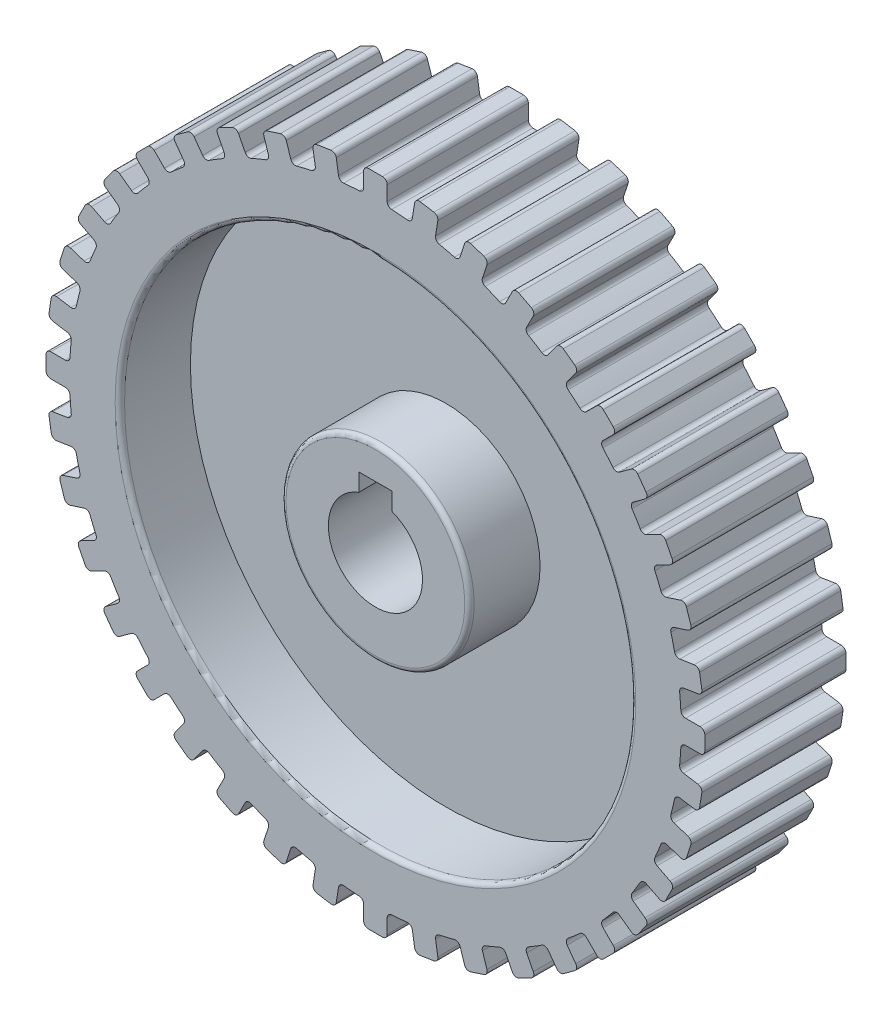
from build123d import *

# Parameters (mm, degrees)
BOSS_EXTRUDE1_DEPTH = 30
CUT_EXTRUDE1_DEPTH  = 30
SKETCH3_R           = 54.321512685
SKETCH3_R_2         = 20
CUT_EXTRUDE2_DEPTH  = 15
FILLET2_R           = 1
FILLET3_R           = 1


with BuildPart() as part:
    # Sketch1 → Boss-Extrude1 (new body)
    with BuildSketch(Plane.XY):
        with BuildLine():
            Line((8.324757236, 68.541581664), (7.840926028, 65.486791638))
            ThreePointArc((7.840926028, 65.486791638), (7.462274894, 64.85008445), (6.749400752, 64.648631768))
            ThreePointArc((6.749400752, 64.648631768), (5.099841222, 64.799626693), (3.446969697, 64.908538729))
            ThreePointArc((3.446969697, 64.908538729), (2.774386362, 65.219029279), (2.5, 65.907131632))
            Line((2.5, 65.907131632), (2.5, 69))
            ThreePointArc((2.5, 69), (2.207106781, 69.707106781), (1.5, 70))
            Line((1.5, 70), (-1.5, 70))
            ThreePointArc((-1.5, 70), (-2.207106781, 69.707106781), (-2.5, 69))
            Line((-2.5, 69), (-2.5, 65.907131632))
            ThreePointArc((-2.5, 65.907131632), (-2.774386362, 65.219029279), (-3.446969697, 64.908538729))
            ThreePointArc((-3.446969697, 64.908538729), (-5.099841222, 64.799626693), (-6.749400753, 64.648631768))
            ThreePointArc((-6.749400753, 64.648631768), (-7.462274894, 64.85008445), (-7.840926028, 65.486791638))
            Line((-7.840926028, 65.486791638), (-8.324757236, 68.541581664))
            ThreePointArc((-8.324757236, 68.541581664), (-8.724660325, 69.194164193), (-9.468880042, 69.372835539))
            Line((-9.468880042, 69.372835539), (-12.431945064, 68.903532144))
            ThreePointArc((-12.431945064, 68.903532144), (-13.084527593, 68.503629056), (-13.263198939, 67.759409339))
            Line((-13.263198939, 67.759409339), (-12.779367731, 64.704619313))
            ThreePointArc((-12.779367731, 64.704619313), (-12.942733018, 63.982065158), (-13.558464313, 63.570182047))
            ThreePointArc((-13.558464313, 63.570182047), (-15.173948651, 63.204044826), (-16.779578555, 62.796860937))
            ThreePointArc((-16.779578555, 62.796860937), (-17.515190176, 62.884315317), (-17.988782434, 63.453949495))
            Line((-17.988782434, 63.453949495), (-18.944531321, 66.39544211))
            ThreePointArc((-18.944531321, 66.39544211), (-19.441597338, 66.97743164), (-20.204604832, 67.037481632))
            Line((-20.204604832, 67.037481632), (-23.057774381, 66.110430649))
            ThreePointArc((-23.057774381, 66.110430649), (-23.639763911, 65.613364633), (-23.699813903, 64.850357138))
            Line((-23.699813903, 64.850357138), (-22.744065016, 61.908864523))
            ThreePointArc((-22.744065016, 61.908864523), (-22.792386632, 61.169650248), (-23.336104539, 60.666516506))
            ThreePointArc((-23.336104539, 60.666516506), (-24.874423104, 60.052169613), (-26.396587446, 59.398822978))
            ThreePointArc((-26.396587446, 59.398822978), (-27.136823346, 59.37012564), (-27.693695316, 59.858660524))
            Line((-27.693695316, 59.858660524), (-29.097828172, 62.614426418))
            ThreePointArc((-29.097828172, 62.614426418), (-29.679817701, 63.111492435), (-30.442825196, 63.051442443))
            Line((-30.442825196, 63.051442443), (-33.115844768, 61.689470944))
            ThreePointArc((-33.115844768, 61.689470944), (-33.612910785, 61.107481414), (-33.552860793, 60.34447392))
            Line((-33.552860793, 60.34447392), (-32.148727937, 57.588708026))
            ThreePointArc((-32.148727937, 57.588708026), (-32.080816044, 56.851035538), (-32.539132424, 56.269039988))
            ThreePointArc((-32.539132424, 56.269039988), (-33.962406707, 55.421610683), (-35.363624749, 54.538188865))
            ThreePointArc((-35.363624749, 54.538188865), (-36.090257863, 54.394046431), (-36.716697508, 54.789452672))
            Line((-36.716697508, 54.789452672), (-38.534639922, 57.291635743))
            ThreePointArc((-38.534639922, 57.291635743), (-39.187222452, 57.691538831), (-39.931442169, 57.512867485))
            Line((-39.931442169, 57.512867485), (-42.358493152, 55.749511728))
            ThreePointArc((-42.358493152, 55.749511728), (-42.75839624, 55.096929199), (-42.579724894, 54.352709481))
            Line((-42.579724894, 54.352709481), (-40.76178248, 51.85052641))
            ThreePointArc((-40.76178248, 51.85052641), (-40.579309295, 51.132559656), (-40.940938877, 50.486032959))
            ThreePointArc((-40.940938877, 50.486032959), (-42.214123142, 49.426387764), (-43.459892245, 48.334643539))
            ThreePointArc((-43.459892245, 48.334643539), (-44.155030455, 48.078605276), (-44.835612753, 48.371146659))
            Line((-44.835612753, 48.371146659), (-47.022600949, 50.558134855))
            ThreePointArc((-47.022600949, 50.558134855), (-47.72970773, 50.851028074), (-48.436814511, 50.558134855))
            Line((-48.436814511, 50.558134855), (-50.558134855, 48.436814511))
            ThreePointArc((-50.558134855, 48.436814511), (-50.851028074, 47.72970773), (-50.558134855, 47.022600949))
            Line((-50.558134855, 47.022600949), (-48.371146659, 44.835612753))
            ThreePointArc((-48.371146659, 44.835612753), (-48.078605276, 44.155030455), (-48.334643539, 43.459892245))
            ThreePointArc((-48.334643539, 43.459892245), (-49.426387764, 42.214123141), (-50.486032959, 40.940938877))
            ThreePointArc((-50.486032959, 40.940938877), (-51.132559656, 40.579309295), (-51.85052641, 40.76178248))
            Line((-51.85052641, 40.76178248), (-54.352709481, 42.579724894))
            ThreePointArc((-54.352709481, 42.579724894), (-55.096929199, 42.75839624), (-55.749511728, 42.358493152))
            Line((-55.749511728, 42.358493152), (-57.512867485, 39.931442169))
            ThreePointArc((-57.512867485, 39.931442169), (-57.691538831, 39.187222452), (-57.291635743, 38.534639922))
            Line((-57.291635743, 38.534639922), (-54.789452672, 36.716697508))
            ThreePointArc((-54.789452672, 36.716697508), (-54.394046431, 36.090257863), (-54.538188865, 35.363624749))
            ThreePointArc((-54.538188865, 35.363624749), (-55.421610683, 33.962406707), (-56.269039988, 32.539132424))
            ThreePointArc((-56.269039988, 32.539132424), (-56.851035538, 32.080816044), (-57.588708026, 32.148727937))
            Line((-57.588708026, 32.148727937), (-60.34447392, 33.552860793))
            ThreePointArc((-60.34447392, 33.552860793), (-61.107481414, 33.612910785), (-61.689470944, 33.115844768))
            Line((-61.689470944, 33.115844768), (-63.051442443, 30.442825196))
            ThreePointArc((-63.051442443, 30.442825196), (-63.111492435, 29.679817701), (-62.614426418, 29.097828172))
            Line((-62.614426418, 29.097828172), (-59.858660524, 27.693695316))
            ThreePointArc((-59.858660524, 27.693695316), (-59.37012564, 27.136823346), (-59.398822978, 26.396587446))
            ThreePointArc((-59.398822978, 26.396587446), (-60.052169613, 24.874423104), (-60.666516506, 23.336104539))
            ThreePointArc((-60.666516506, 23.336104539), (-61.169650248, 22.792386632), (-61.908864523, 22.744065016))
            Line((-61.908864523, 22.744065016), (-64.850357138, 23.699813903))
            ThreePointArc((-64.850357138, 23.699813903), (-65.613364633, 23.639763911), (-66.110430649, 23.057774381))
            Line((-66.110430649, 23.057774381), (-67.037481632, 20.204604832))
            ThreePointArc((-67.037481632, 20.204604832), (-66.97743164, 19.441597338), (-66.39544211, 18.944531321))
            Line((-66.39544211, 18.944531321), (-63.453949495, 17.988782434))
            ThreePointArc((-63.453949495, 17.988782434), (-62.884315317, 17.515190176), (-62.796860937, 16.779578555))
            ThreePointArc((-62.796860937, 16.779578555), (-63.204044826, 15.173948651), (-63.570182047, 13.558464313))
            ThreePointArc((-63.570182047, 13.558464313), (-63.982065158, 12.942733018), (-64.704619313, 12.779367731))
            Line((-64.704619313, 12.779367731), (-67.759409339, 13.263198939))
            ThreePointArc((-67.759409339, 13.263198939), (-68.503629056, 13.084527593), (-68.903532144, 12.431945064))
            Line((-68.903532144, 12.431945064), (-69.372835539, 9.468880042))
            ThreePointArc((-69.372835539, 9.468880042), (-69.194164193, 8.724660325), (-68.541581664, 8.324757236))
            Line((-68.541581664, 8.324757236), (-65.486791638, 7.840926028))
            ThreePointArc((-65.486791638, 7.840926028), (-64.85008445, 7.462274894), (-64.648631768, 6.749400752))
            ThreePointArc((-64.648631768, 6.749400752), (-64.799626693, 5.099841222), (-64.908538729, 3.446969697))
            ThreePointArc((-64.908538729, 3.446969697), (-65.219029279, 2.774386362), (-65.907131632, 2.5))
            Line((-65.907131632, 2.5), (-69, 2.5))
            ThreePointArc((-69, 2.5), (-69.707106781, 2.207106781), (-70, 1.5))
            Line((-70, 1.5), (-70, -1.5))
            ThreePointArc((-70, -1.5), (-69.707106781, -2.207106781), (-69, -2.5))
            Line((-69, -2.5), (-65.907131632, -2.5))
            ThreePointArc((-65.907131632, -2.5), (-65.219029279, -2.774386362), (-64.908538729, -3.446969697))
            ThreePointArc((-64.908538729, -3.446969697), (-64.799626693, -5.099841222), (-64.648631768, -6.749400753))
            ThreePointArc((-64.648631768, -6.749400753), (-64.85008445, -7.462274894), (-65.486791638, -7.840926028))
            Line((-65.486791638, -7.840926028), (-68.541581664, -8.324757236))
            ThreePointArc((-68.541581664, -8.324757236), (-69.194164193, -8.724660325), (-69.372835539, -9.468880042))
            Line((-69.372835539, -9.468880042), (-68.903532144, -12.431945064))
            ThreePointArc((-68.903532144, -12.431945064), (-68.503629056, -13.084527593), (-67.759409339, -13.263198939))
            Line((-67.759409339, -13.263198939), (-64.704619313, -12.779367731))
            ThreePointArc((-64.704619313, -12.779367731), (-63.982065158, -12.942733018), (-63.570182047, -13.558464313))
            ThreePointArc((-63.570182047, -13.558464313), (-63.204044826, -15.173948651), (-62.796860937, -16.779578555))
            ThreePointArc((-62.796860937, -16.779578555), (-62.884315317, -17.515190176), (-63.453949495, -17.988782434))
            Line((-63.453949495, -17.988782434), (-66.39544211, -18.944531321))
            ThreePointArc((-66.39544211, -18.944531321), (-66.97743164, -19.441597338), (-67.037481632, -20.204604832))
            Line((-67.037481632, -20.204604832), (-66.110430649, -23.057774381))
            ThreePointArc((-66.110430649, -23.057774381), (-65.613364633, -23.639763911), (-64.850357138, -23.699813903))
            Line((-64.850357138, -23.699813903), (-61.908864523, -22.744065016))
            ThreePointArc((-61.908864523, -22.744065016), (-61.169650248, -22.792386632), (-60.666516506, -23.336104539))
            ThreePointArc((-60.666516506, -23.336104539), (-60.052169613, -24.874423104), (-59.398822978, -26.396587446))
            ThreePointArc((-59.398822978, -26.396587446), (-59.37012564, -27.136823346), (-59.858660524, -27.693695316))
            Line((-59.858660524, -27.693695316), (-62.614426418, -29.097828172))
            ThreePointArc((-62.614426418, -29.097828172), (-63.111492435, -29.679817701), (-63.051442443, -30.442825196))
            Line((-63.051442443, -30.442825196), (-61.689470944, -33.115844768))
            ThreePointArc((-61.689470944, -33.115844768), (-61.107481414, -33.612910785), (-60.34447392, -33.552860793))
            Line((-60.34447392, -33.552860793), (-57.588708026, -32.148727937))
            ThreePointArc((-57.588708026, -32.148727937), (-56.851035538, -32.080816044), (-56.269039988, -32.539132424))
            ThreePointArc((-56.269039988, -32.539132424), (-55.421610683, -33.962406707), (-54.538188865, -35.363624749))
            ThreePointArc((-54.538188865, -35.363624749), (-54.394046431, -36.090257863), (-54.789452672, -36.716697508))
            Line((-54.789452672, -36.716697508), (-57.291635743, -38.534639922))
            ThreePointArc((-57.291635743, -38.534639922), (-57.691538831, -39.187222452), (-57.512867485, -39.931442169))
            Line((-57.512867485, -39.931442169), (-55.749511728, -42.358493152))
            ThreePointArc((-55.749511728, -42.358493152), (-55.096929199, -42.75839624), (-54.352709481, -42.579724894))
            Line((-54.352709481, -42.579724894), (-51.85052641, -40.76178248))
            ThreePointArc((-51.85052641, -40.76178248), (-51.132559656, -40.579309295), (-50.486032959, -40.940938877))
            ThreePointArc((-50.486032959, -40.940938877), (-49.426387764, -42.214123142), (-48.334643539, -43.459892245))
            ThreePointArc((-48.334643539, -43.459892245), (-48.078605276, -44.155030455), (-48.371146659, -44.835612753))
            Line((-48.371146659, -44.835612753), (-50.558134855, -47.022600949))
            ThreePointArc((-50.558134855, -47.022600949), (-50.851028074, -47.72970773), (-50.558134855, -48.436814511))
            Line((-50.558134855, -48.436814511), (-48.436814511, -50.558134855))
            ThreePointArc((-48.436814511, -50.558134855), (-47.72970773, -50.851028074), (-47.022600949, -50.558134855))
            Line((-47.022600949, -50.558134855), (-44.835612753, -48.371146659))
            ThreePointArc((-44.835612753, -48.371146659), (-44.155030455, -48.078605276), (-43.459892245, -48.334643539))
            ThreePointArc((-43.459892245, -48.334643539), (-42.214123141, -49.426387764), (-40.940938877, -50.486032959))
            ThreePointArc((-40.940938877, -50.486032959), (-40.579309295, -51.132559656), (-40.76178248, -51.85052641))
            Line((-40.76178248, -51.85052641), (-42.579724894, -54.352709481))
            ThreePointArc((-42.579724894, -54.352709481), (-42.75839624, -55.096929199), (-42.358493152, -55.749511728))
            Line((-42.358493152, -55.749511728), (-39.931442169, -57.512867485))
            ThreePointArc((-39.931442169, -57.512867485), (-39.187222452, -57.691538831), (-38.534639922, -57.291635743))
            Line((-38.534639922, -57.291635743), (-36.716697508, -54.789452672))
            ThreePointArc((-36.716697508, -54.789452672), (-36.090257863, -54.394046431), (-35.363624749, -54.538188865))
            ThreePointArc((-35.363624749, -54.538188865), (-33.962406707, -55.421610683), (-32.539132424, -56.269039988))
            ThreePointArc((-32.539132424, -56.269039988), (-32.080816044, -56.851035538), (-32.148727937, -57.588708026))
            Line((-32.148727937, -57.588708026), (-33.552860793, -60.34447392))
            ThreePointArc((-33.552860793, -60.34447392), (-33.612910785, -61.107481414), (-33.115844768, -61.689470944))
            Line((-33.115844768, -61.689470944), (-30.442825196, -63.051442443))
            ThreePointArc((-30.442825196, -63.051442443), (-29.679817701, -63.111492435), (-29.097828172, -62.614426418))
            Line((-29.097828172, -62.614426418), (-27.693695316, -59.858660524))
            ThreePointArc((-27.693695316, -59.858660524), (-27.136823346, -59.37012564), (-26.396587446, -59.398822978))
            ThreePointArc((-26.396587446, -59.398822978), (-24.874423104, -60.052169613), (-23.336104539, -60.666516506))
            ThreePointArc((-23.336104539, -60.666516506), (-22.792386632, -61.169650248), (-22.744065016, -61.908864523))
            Line((-22.744065016, -61.908864523), (-23.699813903, -64.850357138))
            ThreePointArc((-23.699813903, -64.850357138), (-23.639763911, -65.613364633), (-23.057774381, -66.110430649))
            Line((-23.057774381, -66.110430649), (-20.204604832, -67.037481632))
            ThreePointArc((-20.204604832, -67.037481632), (-19.441597338, -66.97743164), (-18.944531321, -66.39544211))
            Line((-18.944531321, -66.39544211), (-17.988782434, -63.453949495))
            ThreePointArc((-17.988782434, -63.453949495), (-17.515190176, -62.884315317), (-16.779578555, -62.796860937))
            ThreePointArc((-16.779578555, -62.796860937), (-15.173948651, -63.204044826), (-13.558464313, -63.570182047))
            ThreePointArc((-13.558464313, -63.570182047), (-12.942733018, -63.982065158), (-12.779367731, -64.704619313))
            Line((-12.779367731, -64.704619313), (-13.263198939, -67.759409339))
            ThreePointArc((-13.263198939, -67.759409339), (-13.084527593, -68.503629056), (-12.431945064, -68.903532144))
            Line((-12.431945064, -68.903532144), (-9.468880042, -69.372835539))
            ThreePointArc((-9.468880042, -69.372835539), (-8.724660325, -69.194164193), (-8.324757236, -68.541581664))
            Line((-8.324757236, -68.541581664), (-7.840926028, -65.486791638))
            ThreePointArc((-7.840926028, -65.486791638), (-7.462274894, -64.85008445), (-6.749400752, -64.648631768))
            ThreePointArc((-6.749400752, -64.648631768), (-5.099841222, -64.799626693), (-3.446969697, -64.908538729))
            ThreePointArc((-3.446969697, -64.908538729), (-2.774386362, -65.219029279), (-2.5, -65.907131632))
            Line((-2.5, -65.907131632), (-2.5, -69))
            ThreePointArc((-2.5, -69), (-2.207106781, -69.707106781), (-1.5, -70))
            Line((-1.5, -70), (1.5, -70))
            ThreePointArc((1.5, -70), (2.207106781, -69.707106781), (2.5, -69))
            Line((2.5, -69), (2.5, -65.907131632))
            ThreePointArc((2.5, -65.907131632), (2.774386362, -65.219029279), (3.446969697, -64.908538729))
            ThreePointArc((3.446969697, -64.908538729), (5.099841222, -64.799626693), (6.749400753, -64.648631768))
            ThreePointArc((6.749400753, -64.648631768), (7.462274894, -64.85008445), (7.840926028, -65.486791638))
            Line((7.840926028, -65.486791638), (8.324757236, -68.541581664))
            ThreePointArc((8.324757236, -68.541581664), (8.724660325, -69.194164193), (9.468880042, -69.372835539))
            Line((9.468880042, -69.372835539), (12.431945064, -68.903532144))
            ThreePointArc((12.431945064, -68.903532144), (13.084527593, -68.503629056), (13.263198939, -67.759409339))
            Line((13.263198939, -67.759409339), (12.779367731, -64.704619313))
            ThreePointArc((12.779367731, -64.704619313), (12.942733018, -63.982065158), (13.558464313, -63.570182047))
            ThreePointArc((13.558464313, -63.570182047), (15.173948651, -63.204044826), (16.779578555, -62.796860937))
            ThreePointArc((16.779578555, -62.796860937), (17.515190176, -62.884315317), (17.988782434, -63.453949495))
            Line((17.988782434, -63.453949495), (18.944531321, -66.39544211))
            ThreePointArc((18.944531321, -66.39544211), (19.441597338, -66.97743164), (20.204604832, -67.037481632))
            Line((20.204604832, -67.037481632), (23.057774381, -66.110430649))
            ThreePointArc((23.057774381, -66.110430649), (23.639763911, -65.613364633), (23.699813903, -64.850357138))
            Line((23.699813903, -64.850357138), (22.744065016, -61.908864523))
            ThreePointArc((22.744065016, -61.908864523), (22.792386632, -61.169650248), (23.336104539, -60.666516506))
            ThreePointArc((23.336104539, -60.666516506), (24.874423104, -60.052169613), (26.396587446, -59.398822978))
            ThreePointArc((26.396587446, -59.398822978), (27.136823346, -59.37012564), (27.693695316, -59.858660524))
            Line((27.693695316, -59.858660524), (29.097828172, -62.614426418))
            ThreePointArc((29.097828172, -62.614426418), (29.679817701, -63.111492435), (30.442825196, -63.051442443))
            Line((30.442825196, -63.051442443), (33.115844768, -61.689470944))
            ThreePointArc((33.115844768, -61.689470944), (33.612910785, -61.107481414), (33.552860793, -60.34447392))
            Line((33.552860793, -60.34447392), (32.148727937, -57.588708026))
            ThreePointArc((32.148727937, -57.588708026), (32.080816044, -56.851035538), (32.539132424, -56.269039988))
            ThreePointArc((32.539132424, -56.269039988), (33.962406707, -55.421610683), (35.363624749, -54.538188865))
            ThreePointArc((35.363624749, -54.538188865), (36.090257863, -54.394046431), (36.716697508, -54.789452672))
            Line((36.716697508, -54.789452672), (38.534639922, -57.291635743))
            ThreePointArc((38.534639922, -57.291635743), (39.187222452, -57.691538831), (39.931442169, -57.512867485))
            Line((39.931442169, -57.512867485), (42.358493152, -55.749511728))
            ThreePointArc((42.358493152, -55.749511728), (42.75839624, -55.096929199), (42.579724894, -54.352709481))
            Line((42.579724894, -54.352709481), (40.76178248, -51.85052641))
            ThreePointArc((40.76178248, -51.85052641), (40.579309295, -51.132559656), (40.940938877, -50.486032959))
            ThreePointArc((40.940938877, -50.486032959), (42.214123142, -49.426387764), (43.459892245, -48.334643539))
            ThreePointArc((43.459892245, -48.334643539), (44.155030455, -48.078605276), (44.835612753, -48.371146659))
            Line((44.835612753, -48.371146659), (47.022600949, -50.558134855))
            ThreePointArc((47.022600949, -50.558134855), (47.72970773, -50.851028074), (48.436814511, -50.558134855))
            Line((48.436814511, -50.558134855), (50.558134855, -48.436814511))
            ThreePointArc((50.558134855, -48.436814511), (50.851028074, -47.72970773), (50.558134855, -47.022600949))
            Line((50.558134855, -47.022600949), (48.371146659, -44.835612753))
            ThreePointArc((48.371146659, -44.835612753), (48.078605276, -44.155030455), (48.334643539, -43.459892245))
            ThreePointArc((48.334643539, -43.459892245), (49.426387764, -42.214123141), (50.486032959, -40.940938877))
            ThreePointArc((50.486032959, -40.940938877), (51.132559656, -40.579309295), (51.85052641, -40.76178248))
            Line((51.85052641, -40.76178248), (54.352709481, -42.579724894))
            ThreePointArc((54.352709481, -42.579724894), (55.096929199, -42.75839624), (55.749511728, -42.358493152))
            Line((55.749511728, -42.358493152), (57.512867485, -39.931442169))
            ThreePointArc((57.512867485, -39.931442169), (57.691538831, -39.187222452), (57.291635743, -38.534639922))
            Line((57.291635743, -38.534639922), (54.789452672, -36.716697508))
            ThreePointArc((54.789452672, -36.716697508), (54.394046431, -36.090257863), (54.538188865, -35.363624749))
            ThreePointArc((54.538188865, -35.363624749), (55.421610683, -33.962406707), (56.269039988, -32.539132424))
            ThreePointArc((56.269039988, -32.539132424), (56.851035538, -32.080816044), (57.588708026, -32.148727937))
            Line((57.588708026, -32.148727937), (60.34447392, -33.552860793))
            ThreePointArc((60.34447392, -33.552860793), (61.107481414, -33.612910785), (61.689470944, -33.115844768))
            Line((61.689470944, -33.115844768), (63.051442443, -30.442825196))
            ThreePointArc((63.051442443, -30.442825196), (63.111492435, -29.679817701), (62.614426418, -29.097828172))
            Line((62.614426418, -29.097828172), (59.858660524, -27.693695316))
            ThreePointArc((59.858660524, -27.693695316), (59.37012564, -27.136823346), (59.398822978, -26.396587446))
            ThreePointArc((59.398822978, -26.396587446), (60.052169613, -24.874423104), (60.666516506, -23.336104539))
            ThreePointArc((60.666516506, -23.336104539), (61.169650248, -22.792386632), (61.908864523, -22.744065016))
            Line((61.908864523, -22.744065016), (64.850357138, -23.699813903))
            ThreePointArc((64.850357138, -23.699813903), (65.613364633, -23.639763911), (66.110430649, -23.057774381))
            Line((66.110430649, -23.057774381), (67.037481632, -20.204604832))
            ThreePointArc((67.037481632, -20.204604832), (66.97743164, -19.441597338), (66.39544211, -18.944531321))
            Line((66.39544211, -18.944531321), (63.453949495, -17.988782434))
            ThreePointArc((63.453949495, -17.988782434), (62.884315317, -17.515190176), (62.796860937, -16.779578555))
            ThreePointArc((62.796860937, -16.779578555), (63.204044826, -15.173948651), (63.570182047, -13.558464313))
            ThreePointArc((63.570182047, -13.558464313), (63.982065158, -12.942733018), (64.704619313, -12.779367731))
            Line((64.704619313, -12.779367731), (67.759409339, -13.263198939))
            ThreePointArc((67.759409339, -13.263198939), (68.503629056, -13.084527593), (68.903532144, -12.431945064))
            Line((68.903532144, -12.431945064), (69.372835539, -9.468880042))
            ThreePointArc((69.372835539, -9.468880042), (69.194164193, -8.724660325), (68.541581664, -8.324757236))
            Line((68.541581664, -8.324757236), (65.486791638, -7.840926028))
            ThreePointArc((65.486791638, -7.840926028), (64.85008445, -7.462274894), (64.648631768, -6.749400752))
            ThreePointArc((64.648631768, -6.749400752), (64.799626693, -5.099841222), (64.908538729, -3.446969697))
            ThreePointArc((64.908538729, -3.446969697), (65.219029279, -2.774386362), (65.907131632, -2.5))
            Line((65.907131632, -2.5), (69, -2.5))
            ThreePointArc((69, -2.5), (69.707106781, -2.207106781), (70, -1.5))
            Line((70, -1.5), (70, 1.5))
            ThreePointArc((70, 1.5), (69.707106781, 2.207106781), (69, 2.5))
            Line((69, 2.5), (65.907131632, 2.5))
            ThreePointArc((65.907131632, 2.5), (65.219029279, 2.774386362), (64.908538729, 3.446969697))
            ThreePointArc((64.908538729, 3.446969697), (64.799626693, 5.099841222), (64.648631768, 6.749400753))
            ThreePointArc((64.648631768, 6.749400753), (64.85008445, 7.462274894), (65.486791638, 7.840926028))
            Line((65.486791638, 7.840926028), (68.541581664, 8.324757236))
            ThreePointArc((68.541581664, 8.324757236), (69.194164193, 8.724660325), (69.372835539, 9.468880042))
            Line((69.372835539, 9.468880042), (68.903532144, 12.431945064))
            ThreePointArc((68.903532144, 12.431945064), (68.503629056, 13.084527593), (67.759409339, 13.263198939))
            Line((67.759409339, 13.263198939), (64.704619313, 12.779367731))
            ThreePointArc((64.704619313, 12.779367731), (63.982065158, 12.942733018), (63.570182047, 13.558464313))
            ThreePointArc((63.570182047, 13.558464313), (63.204044826, 15.173948651), (62.796860937, 16.779578555))
            ThreePointArc((62.796860937, 16.779578555), (62.884315317, 17.515190176), (63.453949495, 17.988782434))
            Line((63.453949495, 17.988782434), (66.39544211, 18.944531321))
            ThreePointArc((66.39544211, 18.944531321), (66.97743164, 19.441597338), (67.037481632, 20.204604832))
            Line((67.037481632, 20.204604832), (66.110430649, 23.057774381))
            ThreePointArc((66.110430649, 23.057774381), (65.613364633, 23.639763911), (64.850357138, 23.699813903))
            Line((64.850357138, 23.699813903), (61.908864523, 22.744065016))
            ThreePointArc((61.908864523, 22.744065016), (61.169650248, 22.792386632), (60.666516506, 23.336104539))
            ThreePointArc((60.666516506, 23.336104539), (60.052169613, 24.874423104), (59.398822978, 26.396587446))
            ThreePointArc((59.398822978, 26.396587446), (59.37012564, 27.136823346), (59.858660524, 27.693695316))
            Line((59.858660524, 27.693695316), (62.614426418, 29.097828172))
            ThreePointArc((62.614426418, 29.097828172), (63.111492435, 29.679817701), (63.051442443, 30.442825196))
            Line((63.051442443, 30.442825196), (61.689470944, 33.115844768))
            ThreePointArc((61.689470944, 33.115844768), (61.107481414, 33.612910785), (60.34447392, 33.552860793))
            Line((60.34447392, 33.552860793), (57.588708026, 32.148727937))
            ThreePointArc((57.588708026, 32.148727937), (56.851035538, 32.080816044), (56.269039988, 32.539132424))
            ThreePointArc((56.269039988, 32.539132424), (55.421610683, 33.962406707), (54.538188865, 35.363624749))
            ThreePointArc((54.538188865, 35.363624749), (54.394046431, 36.090257863), (54.789452672, 36.716697508))
            Line((54.789452672, 36.716697508), (57.291635743, 38.534639922))
            ThreePointArc((57.291635743, 38.534639922), (57.691538831, 39.187222452), (57.512867485, 39.931442169))
            Line((57.512867485, 39.931442169), (55.749511728, 42.358493152))
            ThreePointArc((55.749511728, 42.358493152), (55.096929199, 42.75839624), (54.352709481, 42.579724894))
            Line((54.352709481, 42.579724894), (51.85052641, 40.76178248))
            ThreePointArc((51.85052641, 40.76178248), (51.132559656, 40.579309295), (50.486032959, 40.940938877))
            ThreePointArc((50.486032959, 40.940938877), (49.426387764, 42.214123142), (48.334643539, 43.459892245))
            ThreePointArc((48.334643539, 43.459892245), (48.078605276, 44.155030455), (48.371146659, 44.835612753))
            Line((48.371146659, 44.835612753), (50.558134855, 47.022600949))
            ThreePointArc((50.558134855, 47.022600949), (50.851028074, 47.72970773), (50.558134855, 48.436814511))
            Line((50.558134855, 48.436814511), (48.436814511, 50.558134855))
            ThreePointArc((48.436814511, 50.558134855), (47.72970773, 50.851028074), (47.022600949, 50.558134855))
            Line((47.022600949, 50.558134855), (44.835612753, 48.371146659))
            ThreePointArc((44.835612753, 48.371146659), (44.155030455, 48.078605276), (43.459892245, 48.334643539))
            ThreePointArc((43.459892245, 48.334643539), (42.214123141, 49.426387764), (40.940938877, 50.486032959))
            ThreePointArc((40.940938877, 50.486032959), (40.579309295, 51.132559656), (40.76178248, 51.85052641))
            Line((40.76178248, 51.85052641), (42.579724894, 54.352709481))
            ThreePointArc((42.579724894, 54.352709481), (42.75839624, 55.096929199), (42.358493152, 55.749511728))
            Line((42.358493152, 55.749511728), (39.931442169, 57.512867485))
            ThreePointArc((39.931442169, 57.512867485), (39.187222452, 57.691538831), (38.534639922, 57.291635743))
            Line((38.534639922, 57.291635743), (36.716697508, 54.789452672))
            ThreePointArc((36.716697508, 54.789452672), (36.090257863, 54.394046431), (35.363624749, 54.538188865))
            ThreePointArc((35.363624749, 54.538188865), (33.962406707, 55.421610683), (32.539132424, 56.269039988))
            ThreePointArc((32.539132424, 56.269039988), (32.080816044, 56.851035538), (32.148727937, 57.588708026))
            Line((32.148727937, 57.588708026), (33.552860793, 60.34447392))
            ThreePointArc((33.552860793, 60.34447392), (33.612910785, 61.107481414), (33.115844768, 61.689470944))
            Line((33.115844768, 61.689470944), (30.442825196, 63.051442443))
            ThreePointArc((30.442825196, 63.051442443), (29.679817701, 63.111492435), (29.097828172, 62.614426418))
            Line((29.097828172, 62.614426418), (27.693695316, 59.858660524))
            ThreePointArc((27.693695316, 59.858660524), (27.136823346, 59.37012564), (26.396587446, 59.398822978))
            ThreePointArc((26.396587446, 59.398822978), (24.874423104, 60.052169613), (23.336104539, 60.666516506))
            ThreePointArc((23.336104539, 60.666516506), (22.792386632, 61.169650248), (22.744065016, 61.908864523))
            Line((22.744065016, 61.908864523), (23.699813903, 64.850357138))
            ThreePointArc((23.699813903, 64.850357138), (23.639763911, 65.613364633), (23.057774381, 66.110430649))
            Line((23.057774381, 66.110430649), (20.204604832, 67.037481632))
            ThreePointArc((20.204604832, 67.037481632), (19.441597338, 66.97743164), (18.944531321, 66.39544211))
            Line((18.944531321, 66.39544211), (17.988782434, 63.453949495))
            ThreePointArc((17.988782434, 63.453949495), (17.515190176, 62.884315317), (16.779578555, 62.796860937))
            ThreePointArc((16.779578555, 62.796860937), (15.173948651, 63.204044826), (13.558464313, 63.570182047))
            ThreePointArc((13.558464313, 63.570182047), (12.942733018, 63.982065158), (12.779367731, 64.704619313))
            Line((12.779367731, 64.704619313), (13.263198939, 67.759409339))
            ThreePointArc((13.263198939, 67.759409339), (13.084527593, 68.503629056), (12.431945064, 68.903532144))
            Line((12.431945064, 68.903532144), (9.468880042, 69.372835539))
            ThreePointArc((9.468880042, 69.372835539), (8.724660325, 69.194164193), (8.324757236, 68.541581664))
        make_face()
    extrude(amount=BOSS_EXTRUDE1_DEPTH)

    # Sketch2 → Cut-Extrude1 (cut)
    with BuildSketch(Plane.XY.offset(30)):
        with BuildLine():
            Line((-3.538659763, 13.11467819), (3.538659763, 13.11467819))
            Line((3.538659763, 13.11467819), (3.538659763, 9.352961407))
            ThreePointArc((3.538659763, 9.352961407), (0, -10), (-3.538659763, 9.352961407))
            Line((-3.538659763, 9.352961407), (-3.538659763, 13.11467819))
        make_face()
    extrude(amount=-CUT_EXTRUDE1_DEPTH, mode=Mode.SUBTRACT)

    # Sketch3 → Cut-Extrude2 (cut)
    with BuildSketch(Plane.XY.offset(30)):
        Circle(SKETCH3_R)
        Circle(SKETCH3_R_2, mode=Mode.SUBTRACT)
    extrude(amount=-CUT_EXTRUDE2_DEPTH, mode=Mode.SUBTRACT)

    # Fillet2
    fillet2_edges = [part.edges().sort_by_distance(p)[0] for p in [
        (-54.321512685, 0, 30),
    ]]
    fillet(fillet2_edges, radius=FILLET2_R)

    # Fillet3
    fillet3_edges = [part.edges().sort_by_distance(p)[0] for p in [
        (-20, 0, 30),
    ]]
    fillet(fillet3_edges, radius=FILLET3_R)


solid = part.part
